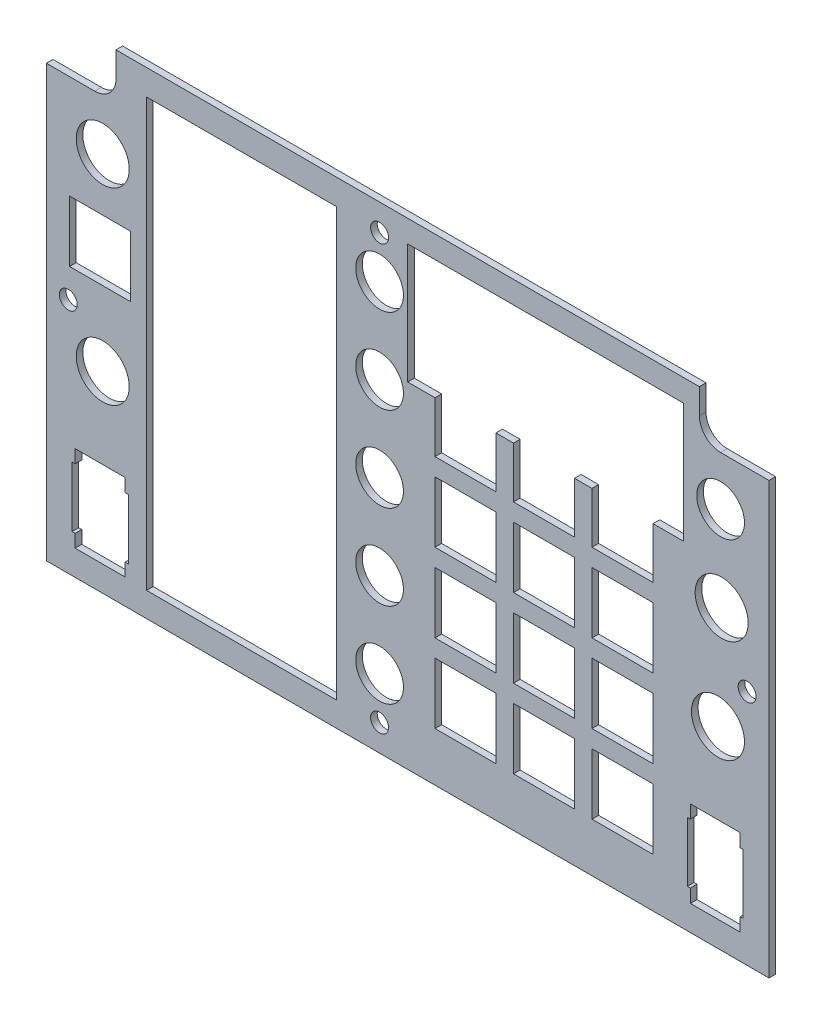
from build123d import *

# Parameters (mm, degrees)
BOSS_EXTRUDE1_DEPTH   = 1.5875
SKETCH2_R             = 6.35
SKETCH2_R_2           = 5.715
SKETCH2_W             = 11.94
SKETCH2_H             = 20.64
SKETCH2_W_2           = 14.605
SKETCH2_H_2           = 14.605
SKETCH2_W_3           = 45.462
SKETCH2_H_3           = 102.32
CUT_EXTRUDE1_DEPTH    = 2.5875
F_6_CLEARANCE_HOLE2_D = 4.3053
CUT_EXTRUDE2_START    = -1.5875
SKETCH7_W             = 13.332833865
SKETCH7_H             = 14.312726798
SKETCH7_W_2           = 13.529020254
SKETCH7_H_2           = 14.424558237
CUT_EXTRUDE2_DEPTH    = 1.5875


with BuildPart() as part:
    # Sketch1 → Boss-Extrude1 (new body)
    with BuildSketch(Plane.XY):
        with BuildLine():
            Line((58.206752076, 169.534029068), (58.206752076, 175.566529068))
            Line((58.206752076, 175.566529068), (-81.493247924, 175.566529068))
            Line((-81.493247924, 175.566529068), (-81.493247924, 169.534029068))
            ThreePointArc((-81.493247924, 169.534029068), (-82.981145475, 165.941926619), (-86.573247924, 164.454029068))
            Line((-86.573247924, 164.454029068), (-98.161997924, 164.454029068))
            Line((-98.161997924, 164.454029068), (-98.161997924, 61.266529068))
            Line((-98.161997924, 61.266529068), (74.875502076, 61.266529068))
            Line((74.875502076, 61.266529068), (74.875502076, 164.454029068))
            Line((74.875502076, 164.454029068), (63.286752076, 164.454029068))
            ThreePointArc((63.286752076, 164.454029068), (59.694649628, 165.941926619), (58.206752076, 169.534029068))
        make_face()
    extrude(amount=BOSS_EXTRUDE1_DEPTH)

    # Sketch2 → Cut-Extrude1 (cut, through all)
    with BuildSketch(Plane.XY.offset(1.5875)):
        with Locations((-84.668247924, 152.389029068)):
            Circle(SKETCH2_R)
        with Locations((-84.668247924, 107.304029068)):
            Circle(SKETCH2_R)
        with Locations((63.540752076, 132.386529068)):
            Circle(SKETCH2_R)
        with Locations((62.651752076, 107.304029068)):
            Circle(SKETCH2_R)
        with Locations((-18.374247924, 77.776529068)):
            Circle(SKETCH2_R_2)
        with Locations((-18.374247924, 98.096529068)):
            Circle(SKETCH2_R_2)
        with Locations((-18.374247924, 118.416529068)):
            Circle(SKETCH2_R_2)
        with Locations((-18.374247924, 138.736529068)):
            Circle(SKETCH2_R_2)
        with Locations((-18.374247924, 159.056529068)):
            Circle(SKETCH2_R_2)
        with Locations((63.286752076, 152.706529068)):
            Circle(SKETCH2_R_2)
        with Locations((62.016752076, 77.649529068)):
            Rectangle(SKETCH2_W, SKETCH2_H)
        with Locations((39.791752076, 80.316529068)):
            Rectangle(SKETCH2_W_2, SKETCH2_H_2)
        with Locations((39.791752076, 99.112529068)):
            Rectangle(SKETCH2_W_2, SKETCH2_H_2)
        with Locations((39.791752076, 117.908529068)):
            Rectangle(SKETCH2_W_2, SKETCH2_H_2)
        with Locations((20.995752076, 80.316529068)):
            Rectangle(SKETCH2_W_2, SKETCH2_H_2)
        Polygon((32.489252076, 141.609529068), (32.489252076, 129.402029068), (47.094252076, 129.402029068), (47.094252076, 141.609529068), (54.396752076, 141.609529068), (54.396752076, 170.249529068), (-11.643247924, 170.249529068), (-11.643247924, 141.609529068), (-5.102747924, 141.609529068), (-5.102747924, 129.402029068), (9.502252076, 129.402029068), (9.502252076, 141.609529068), (13.693252076, 141.609529068), (13.693252076, 129.402029068), (28.298252076, 129.402029068), (28.298252076, 141.609529068), align=None)
        with Locations((20.995752076, 99.112529068)):
            Rectangle(SKETCH2_W_2, SKETCH2_H_2)
        with Locations((20.995752076, 117.908529068)):
            Rectangle(SKETCH2_W_2, SKETCH2_H_2)
        with Locations((2.199752076, 117.908529068)):
            Rectangle(SKETCH2_W_2, SKETCH2_H_2)
        with Locations((2.199752076, 99.112529068)):
            Rectangle(SKETCH2_W_2, SKETCH2_H_2)
        with Locations((2.199752076, 80.316529068)):
            Rectangle(SKETCH2_W_2, SKETCH2_H_2)
        with Locations((-85.303247924, 132.386529068)):
            Rectangle(SKETCH2_W_2, SKETCH2_H_2)
        with Locations((-51.442247924, 118.289529068)):
            Rectangle(SKETCH2_W_3, SKETCH2_H_3)
        with Locations((-85.303247924, 77.649529068)):
            Rectangle(SKETCH2_W, SKETCH2_H)
    extrude(amount=-CUT_EXTRUDE1_DEPTH, mode=Mode.SUBTRACT)

    # #6 Clearance Hole2 (through all)
    with Locations(Plane(origin=(-11.643247924, -6.662700632, -3.175), x_dir=(-1, 0, 0), z_dir=(0, 0, -1))):
        with Locations((-81.28, 124.6982297), (6.731, 175.8792297), (81.28, 124.6982297), (6.731, 74.2792297)):
            Hole(F_6_CLEARANCE_HOLE2_D / 2)

    # Sketch7 → Cut-Extrude2 (cut)
    with BuildSketch(Plane.XY.offset(1.5875).offset(CUT_EXTRUDE2_START)):
        with Locations((62.004967044, 77.673806769)):
            Rectangle(SKETCH7_W, SKETCH7_H)
        with Locations((-85.255785181, 77.616484213)):
            Rectangle(SKETCH7_W_2, SKETCH7_H_2)
    extrude(amount=CUT_EXTRUDE2_DEPTH, mode=Mode.SUBTRACT)


solid = part.part
